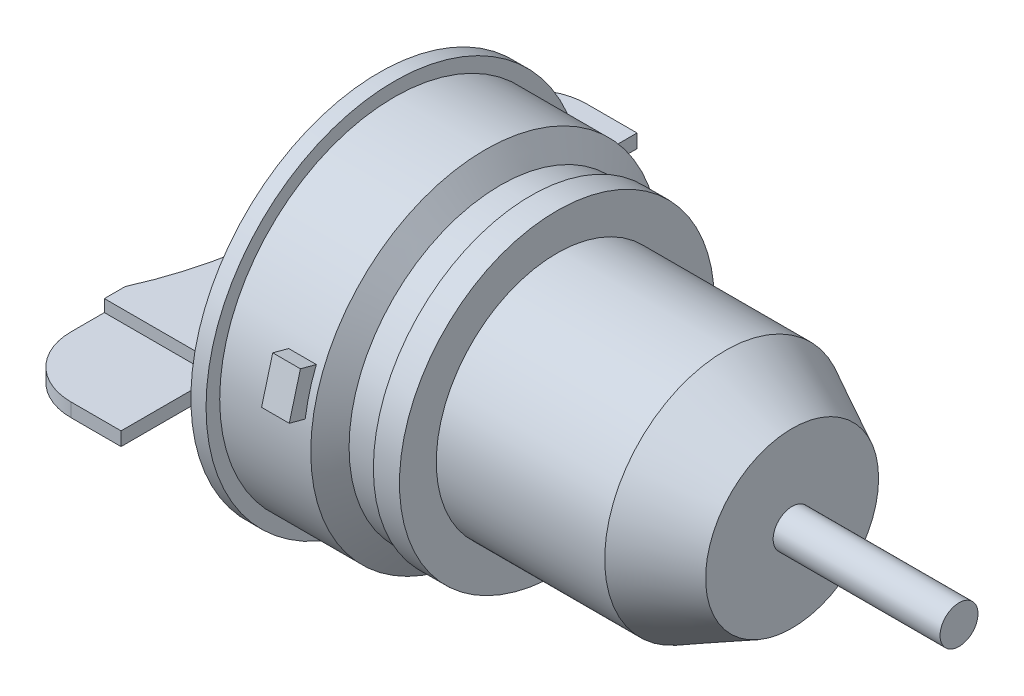
from build123d import *

# Parameters (mm, degrees)
SKETCH1_R           = 20.193
BOSS_EXTRUDE1_DEPTH = 28.194
SKETCH2_R           = 20.193
SKETCH3_R           = 14.478
SKETCH4_R           = 3.175
BOSS_EXTRUDE2_DEPTH = 27.94
SKETCH5_R           = 26.3525
BOSS_EXTRUDE4_DEPTH = 9.4488
SKETCH6_OUTSIDE_W   = 76.102
SKETCH6_OUTSIDE_H   = 76.102
SKETCH6_OUTSIDE_R   = 25.3365
CUT_EXTRUDE1_DEPTH  = 5.08
SKETCH9_R           = 29.21
SKETCH10_R          = 29.21
BOSS_EXTRUDE5_DEPTH = 15.24
SKETCH11_R          = 31.496
BOSS_EXTRUDE6_DEPTH = 2.54
SKETCH14_R          = 22.225
SKETCH12_R          = 20.32
SKETCH15_W          = 18.542
SKETCH15_H          = 6.35
BOSS_EXTRUDE7_DEPTH = 43.18
SKETCH16_W          = 18.542
SKETCH16_H          = 2.032
CUT_EXTRUDE2_DEPTH  = 15.748
SKETCH17_R          = 5.461
BOSS_EXTRUDE8_DEPTH = 10.16
BOSS_EXTRUDE8_TAPER = 1
CUT_EXTRUDE3_REACH  = 89.162
FILLET1_R           = 10.16
FILLET3_R           = 10.16
SKETCH20_W          = 4.6355
SKETCH20_H          = 7.2136
BOSS_EXTRUDE9_DEPTH = 31.75


with BuildPart() as part:
    # Sketch1 → Boss-Extrude1 (new body)
    with BuildSketch(Plane(origin=(0, 0, 0), x_dir=(0, 0, -1), z_dir=(1, 0, 0))):
        Circle(SKETCH1_R)
    extrude(amount=BOSS_EXTRUDE1_DEPTH)

    # Sketch2 → Loft2 section 0
    with BuildSketch(Plane(origin=(28.194, 0, 0), x_dir=(0, 0, -1), z_dir=(1, 0, 0))):
        Circle(SKETCH2_R)
    # Sketch3 → Loft2 section 1
    with BuildSketch(Plane(origin=(39.37, 0, 0), x_dir=(0, 0, -1), z_dir=(1, 0, 0))):
        Circle(SKETCH3_R)
    loft()

    # Sketch4 → Boss-Extrude2 (add)
    with BuildSketch(Plane(origin=(39.37, 0, 0), x_dir=(0, 0, -1), z_dir=(1, 0, 0))):
        Circle(SKETCH4_R)
    extrude(amount=BOSS_EXTRUDE2_DEPTH)

    # Sketch5 → Boss-Extrude4 (add)
    with BuildSketch(Plane(origin=(0, 0, 0), x_dir=(0, 0, -1), z_dir=(1, 0, 0))):
        Circle(SKETCH5_R)
    extrude(amount=-BOSS_EXTRUDE4_DEPTH)

    # Sketch6 outside → Cut-Extrude1 (cut)
    with BuildSketch(Plane.ZY.offset(9.4488)):
        Rectangle(SKETCH6_OUTSIDE_W, SKETCH6_OUTSIDE_H)
        Circle(SKETCH6_OUTSIDE_R, mode=Mode.SUBTRACT)
    extrude(amount=-CUT_EXTRUDE1_DEPTH, mode=Mode.SUBTRACT)

    # Sketch9 → section 0 of loft3
    with BuildSketch(Plane.ZY.offset(11.9888), mode=Mode.PRIVATE) as loft3_s0:
        Circle(SKETCH9_R)
    # loft up to a face of the part (loft3)
    loft([loft3_s0.sketch, Face(Wire([part.edges().sort_by_distance((-9.4488, 18.469513629, -17.344027749))[0]]))])

    # Sketch10 → Boss-Extrude5 (add)
    with BuildSketch(Plane.ZY.offset(11.9888)):
        with Locations(Location((0, 0, 0), (0, 0, 180))):
            Circle(SKETCH10_R)
    extrude(amount=BOSS_EXTRUDE5_DEPTH)

    # Sketch11 → Boss-Extrude6 (add)
    with BuildSketch(Plane.ZY.offset(27.2288)):
        Circle(SKETCH11_R)
    extrude(amount=BOSS_EXTRUDE6_DEPTH)

    # Sketch14 → Loft6 section 0
    with BuildSketch(Plane.ZY.offset(29.7688)):
        Circle(SKETCH14_R)
    # Sketch12 → Loft6 section 1
    with BuildSketch(Plane.ZY.offset(37.3888)):
        Circle(SKETCH12_R)
    loft()

    # Sketch15 → Boss-Extrude7 (add, symmetric)
    with BuildSketch(Plane.XY):
        with Locations((-39.0398, 0)):
            Rectangle(SKETCH15_W, SKETCH15_H)
    extrude(amount=BOSS_EXTRUDE7_DEPTH, both=True)

    # Sketch16 → Cut-Extrude2 (cut)
    with BuildSketch(Plane.XY.offset(43.18)):
        with Locations((-39.0398, 2.159)):
            Rectangle(SKETCH16_W, SKETCH16_H)
        with Locations((-39.0398, -2.159)):
            Rectangle(SKETCH16_W, SKETCH16_H)
    cut_extrude2 = extrude(amount=-CUT_EXTRUDE2_DEPTH, mode=Mode.SUBTRACT)

    # Mirror1: Cut-Extrude2 across plane
    add(cut_extrude2.mirror(Plane.XY), mode=Mode.SUBTRACT)

    # Sketch17 → Boss-Extrude8 (add)
    with BuildSketch(Plane.ZY.offset(37.3888)):
        with Locations((0, -11.811)):
            Circle(SKETCH17_R)
    extrude(amount=BOSS_EXTRUDE8_DEPTH, taper=BOSS_EXTRUDE8_TAPER)

    # Sketch18 → Cut-Extrude3 (cut, up to next)
    with BuildSketch(Plane(origin=(0, 3.175, 0), x_dir=(1, 0, 0), z_dir=(0, 1, 0)), mode=Mode.PRIVATE) as cut_extrude3_sk1:
        with BuildLine():
            Line((-48.3108, 23.940709333), (-48.3108, -23.940709333))
            ThreePointArc((-48.3108, -23.940709333), (-43.18, 0), (-48.3108, 23.940709333))
        make_face()
    cut_extrude3_tool1 = extrude(cut_extrude3_sk1.sketch, amount=-CUT_EXTRUDE3_REACH, mode=Mode.PRIVATE) & part.part
    add(cut_extrude3_tool1.solids().sort_by_distance((-46.250554, 3.175, 0))[0], mode=Mode.SUBTRACT)

    # Fillet1
    fillet1_edges = [part.edges().sort_by_distance(p)[0] for p in [
        (-48.3108, 0, -43.18),
    ]]
    fillet(fillet1_edges, radius=FILLET1_R)

    # Fillet3
    fillet3_edges = [part.edges().sort_by_distance(p)[0] for p in [
        (-48.3108, 0, 43.18),
    ]]
    fillet(fillet3_edges, radius=FILLET3_R)

    # Sketch20 → Boss-Extrude9 (add, symmetric)
    with BuildSketch(Plane(origin=(0, 0, 0), x_dir=(-1, 0, 0), z_dir=(0, -0.25881904510250753, -0.9659258262890719))):
        with Locations((15.51305, 0)):
            Rectangle(SKETCH20_W, SKETCH20_H)
    extrude(amount=BOSS_EXTRUDE9_DEPTH, both=True)


solid = part.part
